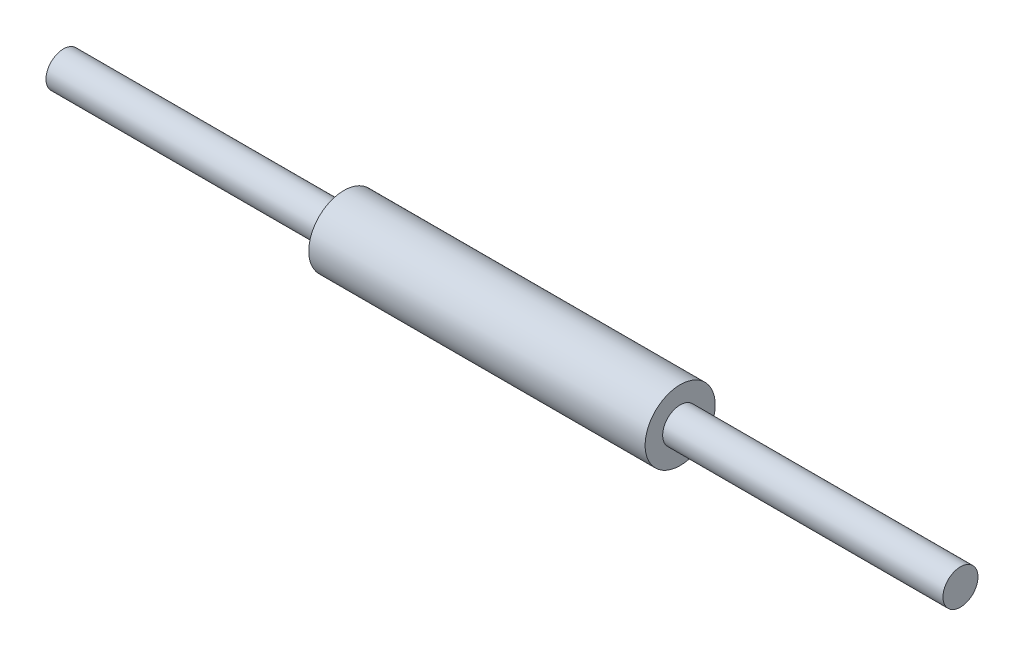
from build123d import *

# Parameters (mm, degrees)
SKETCH2_R            = 12.5
BOSS_EXTRUDEAB_DEPTH = 200
SKETCH3_R            = 25
BOSS_EXTRUDEBC_DEPTH = 240
SKETCH4_R            = 12.5
BOSS_EXTRUDECD_DEPTH = 200


with BuildPart() as part:
    # Sketch2 → Boss-ExtrudeAB (new body)
    with BuildSketch(Plane(origin=(0, 0, 0), x_dir=(0, 0, -1), z_dir=(1, 0, 0))):
        Circle(SKETCH2_R)
    extrude(amount=BOSS_EXTRUDEAB_DEPTH)


with BuildPart() as body_2:
    # Sketch3 → Boss-ExtrudeBC (new body)
    with BuildSketch(Plane(origin=(200, 0, 0), x_dir=(0, 0, -1), z_dir=(1, 0, 0))):
        Circle(SKETCH3_R)
    extrude(amount=BOSS_EXTRUDEBC_DEPTH)


with BuildPart() as body_3:
    # Sketch4 → Boss-ExtrudeCD (new body)
    with BuildSketch(Plane(origin=(440, 0, 0), x_dir=(0, 0, -1), z_dir=(1, 0, 0))):
        Circle(SKETCH4_R)
    extrude(amount=BOSS_EXTRUDECD_DEPTH)


solid = Compound([part.part, body_2.part, body_3.part])
